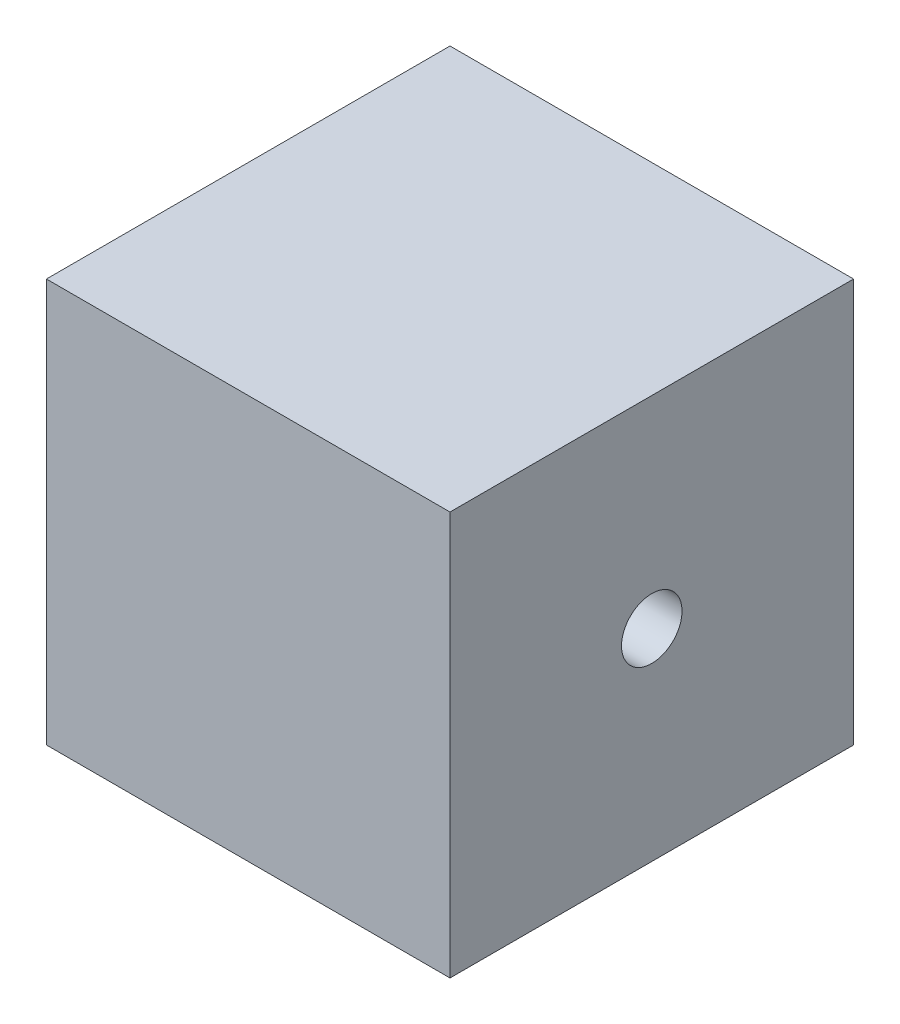
from build123d import *

# Parameters (mm, degrees)
SKETCH1_W           = 20
SKETCH1_H           = 20
BOSS_EXTRUDE1_DEPTH = 20
SKETCH3_R           = 1.5
CUT_EXTRUDE1_DEPTH  = 20


with BuildPart() as part:
    # Sketch1 → Boss-Extrude1 (new body)
    with BuildSketch(Plane(origin=(0, 0, 0), x_dir=(1, 0, 0), z_dir=(0, 1, 0))):
        Rectangle(SKETCH1_W, SKETCH1_H)
    extrude(amount=BOSS_EXTRUDE1_DEPTH)

    # Sketch3 → Cut-Extrude1 (cut)
    with BuildSketch(Plane.ZY.offset(10)):
        with Locations((0, 10)):
            Circle(SKETCH3_R)
    extrude(amount=-CUT_EXTRUDE1_DEPTH, mode=Mode.SUBTRACT)


solid = part.part
